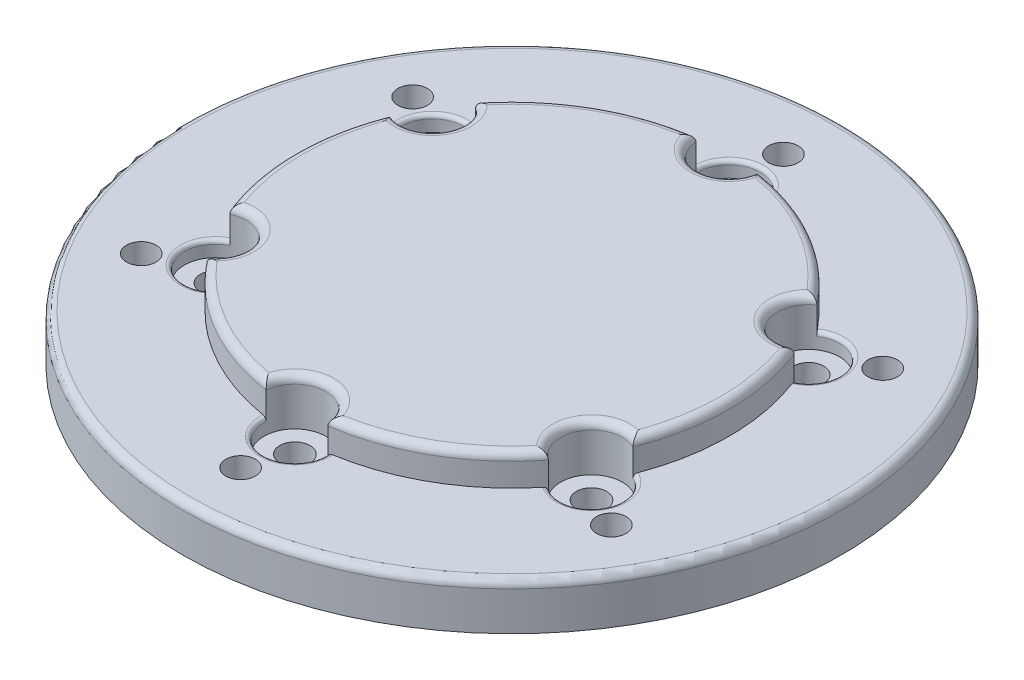
from build123d import *

# Parameters (mm, degrees)
SKETCH1_R           = 42.5
BOSS_EXTRUDE1_DEPTH = 6
SKETCH2_R           = 1.9
CUT_EXTRUDE1_DEPTH  = 34
SKETCH3_R           = 4
CUT_EXTRUDE2_DEPTH  = 2.5
SKETCH4_R           = 28
BOSS_EXTRUDE2_DEPTH = 4
SKETCH5_R           = 1.95
CUT_EXTRUDE3_DEPTH  = 18
SKETCH6_R           = 4
CUT_EXTRUDE4_DEPTH  = 6
FILLET3_R           = 1
FILLET4_R           = 0.5
SKETCH8_R           = 2.1
SKETCH8_R_2         = 1.9
BOSS_EXTRUDE3_DEPTH = 4
SKETCH9_R           = 3
BOSS_EXTRUDE4_DEPTH = 0.4
FILLET5_R           = 1


with BuildPart() as part:
    # Sketch1 → Boss-Extrude1 (new body)
    with BuildSketch(Plane(origin=(0, 0, 0), x_dir=(1, 0, 0), z_dir=(0, 1, 0))):
        Circle(SKETCH1_R)
    extrude(amount=BOSS_EXTRUDE1_DEPTH)

    # Sketch2 → Cut-Extrude1 (cut)
    with BuildSketch(Plane(origin=(0, 6, 0), x_dir=(1, 0, 0), z_dir=(0, 1, 0))):
        with Locations((0, 35)):
            Circle(SKETCH2_R)
        with Locations((-30.310889132, 17.5)):
            Circle(SKETCH2_R)
        with Locations((30.310889132, 17.5)):
            Circle(SKETCH2_R)
        with Locations((30.310889132, -17.5)):
            Circle(SKETCH2_R)
        with Locations((-30.310889132, -17.5)):
            Circle(SKETCH2_R)
        with Locations((0, -35)):
            Circle(SKETCH2_R)
    extrude(amount=-CUT_EXTRUDE1_DEPTH, mode=Mode.SUBTRACT)

    # Sketch3 → Cut-Extrude2 (cut)
    with BuildSketch(Plane.XZ):
        with Locations((0, -35)):
            Circle(SKETCH3_R)
        with Locations((-30.310889132, -17.5)):
            Circle(SKETCH3_R)
        with Locations((-30.310889132, 17.5)):
            Circle(SKETCH3_R)
        with Locations((0, 35)):
            Circle(SKETCH3_R)
        with Locations((30.310889132, 17.5)):
            Circle(SKETCH3_R)
        with Locations((30.310889132, -17.5)):
            Circle(SKETCH3_R)
    extrude(amount=-CUT_EXTRUDE2_DEPTH, mode=Mode.SUBTRACT)

    # Sketch4 → Boss-Extrude2 (add)
    with BuildSketch(Plane(origin=(0, 6, 0), x_dir=(1, 0, 0), z_dir=(0, 1, 0))):
        Circle(SKETCH4_R)
    extrude(amount=BOSS_EXTRUDE2_DEPTH)

    # Sketch5 → Cut-Extrude3 (cut)
    with BuildSketch(Plane(origin=(0, 10, 0), x_dir=(1, 0, 0), z_dir=(0, 1, 0))):
        with Locations((-24.248711306, 14)):
            Circle(SKETCH5_R)
        with Locations((0, 28)):
            Circle(SKETCH5_R)
        with Locations((24.248711306, 14)):
            Circle(SKETCH5_R)
        with Locations((24.248711306, -14)):
            Circle(SKETCH5_R)
        with Locations((0, -28)):
            Circle(SKETCH5_R)
        with Locations((-24.248711306, -14)):
            Circle(SKETCH5_R)
    extrude(amount=-CUT_EXTRUDE3_DEPTH, mode=Mode.SUBTRACT)

    # Sketch6 → Cut-Extrude4 (cut)
    with BuildSketch(Plane(origin=(0, 10, 0), x_dir=(1, 0, 0), z_dir=(0, 1, 0))):
        with Locations((0, 28)):
            Circle(SKETCH6_R)
        with Locations((24.248711306, 14)):
            Circle(SKETCH6_R)
        with Locations((24.248711306, -14)):
            Circle(SKETCH6_R)
        with Locations((0, -28)):
            Circle(SKETCH6_R)
        with Locations((-24.248711306, -14)):
            Circle(SKETCH6_R)
        with Locations((-24.248711306, 14)):
            Circle(SKETCH6_R)
    extrude(amount=-CUT_EXTRUDE4_DEPTH, mode=Mode.SUBTRACT)

    # Fillet3
    fillet3_edges = [part.edges().sort_by_distance(p)[0] for p in [
        (-14, 10, -24.248711306),
        (0, 10, -24),
        (-28, 10, 0),
        (-14, 10, 24.248711306),
        (14, 10, 24.248711306),
        (28, 10, 0),
        (14, 10, -24.248711306),
        (20.784609691, 10, -12),
        (20.784609691, 10, 12),
        (0, 10, 24),
        (-22.126191862, 10, 10.609585393),
        (-22.126191862, 10, -10.609585393),
    ]]
    fillet(fillet3_edges, radius=FILLET3_R)

    # Fillet4
    fillet4_edges = [part.edges().sort_by_distance(p)[0] for p in [
        (-0.142948455, 6, -31.997444901),
        (26.123636763, 6, -17.533363062),
        (26.123636763, 6, 17.533363062),
        (-0.142948455, 6, 31.997444901),
        (-27.712812921, 6, 16),
        (-27.712812921, 6, -16),
    ]]
    fillet(fillet4_edges, radius=FILLET4_R)

    # Sketch8 → Boss-Extrude3 (add)
    with BuildSketch(Plane.XZ):
        with Locations((0, 35)):
            Circle(SKETCH8_R)
        with Locations((0, 35)):
            Circle(SKETCH8_R_2, mode=Mode.SUBTRACT)
        with Locations((30.310889132, 17.5)):
            Circle(SKETCH8_R)
        with Locations((30.310889132, 17.5)):
            Circle(SKETCH8_R_2, mode=Mode.SUBTRACT)
        with Locations((30.310889132, -17.5)):
            Circle(SKETCH8_R)
        with Locations((30.310889132, -17.5)):
            Circle(SKETCH8_R_2, mode=Mode.SUBTRACT)
        with Locations((0, -35)):
            Circle(SKETCH8_R)
        with Locations((0, -35)):
            Circle(SKETCH8_R_2, mode=Mode.SUBTRACT)
        with Locations((-30.310889132, -17.5)):
            Circle(SKETCH8_R)
        with Locations((-30.310889132, -17.5)):
            Circle(SKETCH8_R_2, mode=Mode.SUBTRACT)
        with Locations((-30.310889132, 17.5)):
            Circle(SKETCH8_R)
        with Locations((-30.310889132, 17.5)):
            Circle(SKETCH8_R_2, mode=Mode.SUBTRACT)
    extrude(amount=-BOSS_EXTRUDE3_DEPTH)

    # Sketch9 → Boss-Extrude4 (add)
    with BuildSketch(Plane.XZ):
        with Locations((0, 35)):
            Circle(SKETCH9_R)
        with Locations((30.310889132, 17.5)):
            Circle(SKETCH9_R)
        with Locations((30.310889132, -17.5)):
            Circle(SKETCH9_R)
        with Locations((0, -35)):
            Circle(SKETCH9_R)
        with Locations((-30.310889132, -17.5)):
            Circle(SKETCH9_R)
        with Locations((-30.310889132, 17.5)):
            Circle(SKETCH9_R)
    extrude(amount=-BOSS_EXTRUDE4_DEPTH)

    # Fillet5
    fillet5_edges = [part.edges().sort_by_distance(p)[0] for p in [
        (-42.5, 6, 0),
    ]]
    fillet(fillet5_edges, radius=FILLET5_R)


solid = part.part
